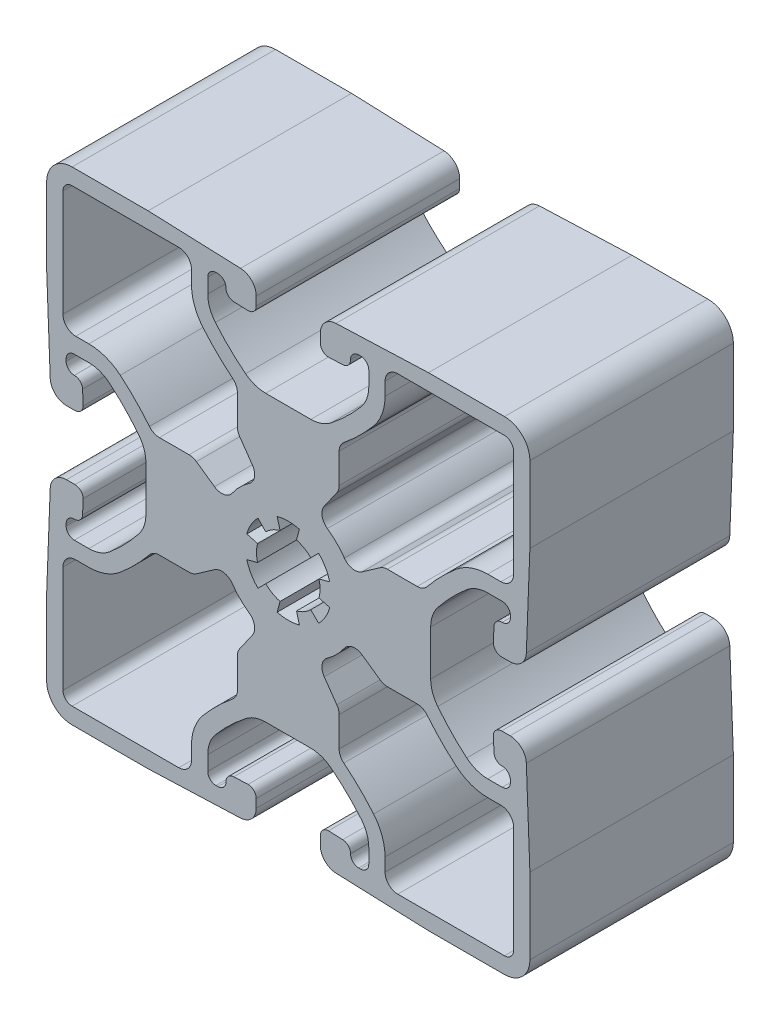
from build123d import *

# Parameters (mm, degrees)
EXTRUDE1_DEPTH = 25.4


with BuildPart() as part:
    # Sketch1 → Extrude1 (new body)
    with BuildSketch(Plane.XY):
        with BuildLine():
            Line((-26.9875, 30.1625), (-17.5006, 30.1625))
            Line((-17.5006, 30.1625), (-5.954495972, 29.718943425))
            ThreePointArc((-5.954495972, 29.718943425), (-4.568340141, 29.097433694), (-4.0005, 27.688441178))
            Line((-4.0005, 27.688441178), (-4.0005, 26.624789016))
            ThreePointArc((-4.0005, 26.624789016), (-4.29807951, 25.906368526), (-5.0165, 25.608789016))
            Line((-5.0165, 25.608789016), (-6.79818433, 25.677234424))
            ThreePointArc((-6.79818433, 25.677234424), (-7.491262245, 25.987989289), (-7.775182316, 26.692485547))
            Line((-7.775182316, 26.692485547), (-7.775182316, 26.715598436))
            ThreePointArc((-7.775182316, 26.715598436), (-8.072761826, 27.434018925), (-8.791182316, 27.731598436))
            Line((-8.791182316, 27.731598436), (-9.034069816, 27.731598436))
            ThreePointArc((-9.034069816, 27.731598436), (-9.752490306, 27.434018925), (-10.050069816, 26.715598436))
            Line((-10.050069816, 26.715598436), (-10.050069816, 24.89924596))
            ThreePointArc((-10.050069816, 24.89924596), (-9.804339489, 23.507515849), (-9.096864747, 22.284088049))
            ThreePointArc((-9.096864747, 22.284088049), (-7.306401028, 20.365015595), (-5.327460613, 18.640952309))
            ThreePointArc((-5.327460613, 18.640952309), (-4.146266021, 17.997592264), (-2.819770332, 17.775011948))
            Line((-2.819770332, 17.775011948), (2.819770332, 17.775011948))
            ThreePointArc((2.819770332, 17.775011948), (4.156955601, 18.004131576), (5.344219335, 18.66061088))
            ThreePointArc((5.344219335, 18.66061088), (7.312093916, 20.374098876), (9.09379166, 22.280436891))
            ThreePointArc((9.09379166, 22.280436891), (9.803521687, 23.50527422), (10.050069816, 24.89924596))
            Line((10.050069816, 24.89924596), (10.050069816, 26.715598436))
            ThreePointArc((10.050069816, 26.715598436), (9.752490306, 27.434018925), (9.034069816, 27.731598436))
            Line((9.034069816, 27.731598436), (8.791182316, 27.731598436))
            ThreePointArc((8.791182316, 27.731598436), (8.072761826, 27.434018925), (7.775182316, 26.715598436))
            Line((7.775182316, 26.715598436), (7.775182316, 26.692485547))
            ThreePointArc((7.775182316, 26.692485547), (7.491262245, 25.987989289), (6.79818433, 25.677234424))
            Line((6.79818433, 25.677234424), (5.0165, 25.608789016))
            ThreePointArc((5.0165, 25.608789016), (4.29807951, 25.906368526), (4.0005, 26.624789016))
            Line((4.0005, 26.624789016), (4.0005, 27.688441178))
            ThreePointArc((4.0005, 27.688441178), (4.568340141, 29.097433694), (5.954495972, 29.718943425))
            Line((5.954495972, 29.718943425), (17.5006, 30.1625))
            Line((17.5006, 30.1625), (26.9875, 30.1625))
            ThreePointArc((26.9875, 30.1625), (29.23256403, 29.23256403), (30.1625, 26.9875))
            Line((30.1625, 26.9875), (30.1625, 17.5006))
            Line((30.1625, 17.5006), (29.718943425, 5.954495972))
            ThreePointArc((29.718943425, 5.954495972), (29.097433694, 4.568340141), (27.688441178, 4.0005))
            Line((27.688441178, 4.0005), (26.624789016, 4.0005))
            ThreePointArc((26.624789016, 4.0005), (25.906368526, 4.29807951), (25.608789016, 5.0165))
            Line((25.608789016, 5.0165), (25.677234424, 6.79818433))
            ThreePointArc((25.677234424, 6.79818433), (25.987989289, 7.491262245), (26.692485547, 7.775182316))
            Line((26.692485547, 7.775182316), (26.715598436, 7.775182316))
            ThreePointArc((26.715598436, 7.775182316), (27.434018925, 8.072761826), (27.731598436, 8.791182316))
            Line((27.731598436, 8.791182316), (27.731598436, 9.034069816))
            ThreePointArc((27.731598436, 9.034069816), (27.434018925, 9.752490306), (26.715598436, 10.050069816))
            Line((26.715598436, 10.050069816), (24.89924596, 10.050069816))
            ThreePointArc((24.89924596, 10.050069816), (23.507515849, 9.804339489), (22.284088049, 9.096864747))
            ThreePointArc((22.284088049, 9.096864747), (20.365015595, 7.306401028), (18.640952309, 5.327460613))
            ThreePointArc((18.640952309, 5.327460613), (17.996266106, 4.142432499), (17.775011948, 2.811658842))
            Line((17.775011948, 2.811658842), (17.775011948, -2.819770332))
            ThreePointArc((17.775011948, -2.819770332), (18.004131576, -4.156955601), (18.66061088, -5.344219335))
            ThreePointArc((18.66061088, -5.344219335), (20.374098876, -7.312093916), (22.280436891, -9.09379166))
            ThreePointArc((22.280436891, -9.09379166), (23.50527422, -9.803521687), (24.89924596, -10.050069816))
            Line((24.89924596, -10.050069816), (26.715598436, -10.050069816))
            ThreePointArc((26.715598436, -10.050069816), (27.434018925, -9.752490306), (27.731598436, -9.034069816))
            Line((27.731598436, -9.034069816), (27.731598436, -8.791182316))
            ThreePointArc((27.731598436, -8.791182316), (27.434018925, -8.072761826), (26.715598436, -7.775182316))
            Line((26.715598436, -7.775182316), (26.692485547, -7.775182316))
            ThreePointArc((26.692485547, -7.775182316), (25.987989289, -7.491262245), (25.677234424, -6.79818433))
            Line((25.677234424, -6.79818433), (25.608789016, -5.0165))
            ThreePointArc((25.608789016, -5.0165), (25.906368526, -4.29807951), (26.624789016, -4.0005))
            Line((26.624789016, -4.0005), (27.688441178, -4.0005))
            ThreePointArc((27.688441178, -4.0005), (29.097433694, -4.568340141), (29.718943425, -5.954495972))
            Line((29.718943425, -5.954495972), (30.1625, -17.5006))
            Line((30.1625, -17.5006), (30.1625, -26.9875))
            ThreePointArc((30.1625, -26.9875), (29.23256403, -29.23256403), (26.9875, -30.1625))
            Line((26.9875, -30.1625), (17.5006, -30.1625))
            Line((17.5006, -30.1625), (5.954495972, -29.718943425))
            ThreePointArc((5.954495972, -29.718943425), (4.568340141, -29.097433694), (4.0005, -27.688441178))
            Line((4.0005, -27.688441178), (4.0005, -26.624789016))
            ThreePointArc((4.0005, -26.624789016), (4.29807951, -25.906368526), (5.0165, -25.608789016))
            Line((5.0165, -25.608789016), (6.79818433, -25.677234424))
            ThreePointArc((6.79818433, -25.677234424), (7.491262245, -25.987989289), (7.775182316, -26.692485547))
            Line((7.775182316, -26.692485547), (7.775182316, -26.715598436))
            ThreePointArc((7.775182316, -26.715598436), (8.072761826, -27.434018925), (8.791182316, -27.731598436))
            Line((8.791182316, -27.731598436), (9.034069816, -27.731598436))
            ThreePointArc((9.034069816, -27.731598436), (9.752490306, -27.434018925), (10.050069816, -26.715598436))
            Line((10.050069816, -26.715598436), (10.050069816, -24.89924596))
            ThreePointArc((10.050069816, -24.89924596), (9.804339489, -23.507515849), (9.096864674, -22.28408811))
            ThreePointArc((9.096864674, -22.28408811), (7.306400962, -20.365015663), (5.327460613, -18.640952309))
            ThreePointArc((5.327460613, -18.640952309), (4.142432499, -17.996266106), (2.811658842, -17.775011948))
            Line((2.811658842, -17.775011948), (-2.811658842, -17.775011948))
            ThreePointArc((-2.811658842, -17.775011948), (-4.153127078, -18.002795196), (-5.344219335, -18.66061088))
            ThreePointArc((-5.344219335, -18.66061088), (-7.312093916, -20.374098876), (-9.09379166, -22.280436891))
            ThreePointArc((-9.09379166, -22.280436891), (-9.803521687, -23.50527422), (-10.050069816, -24.89924596))
            Line((-10.050069816, -24.89924596), (-10.050069816, -26.715598436))
            ThreePointArc((-10.050069816, -26.715598436), (-9.752490306, -27.434018925), (-9.034069816, -27.731598436))
            Line((-9.034069816, -27.731598436), (-8.791182316, -27.731598436))
            ThreePointArc((-8.791182316, -27.731598436), (-8.072761826, -27.434018925), (-7.775182316, -26.715598436))
            Line((-7.775182316, -26.715598436), (-7.775182316, -26.692485547))
            ThreePointArc((-7.775182316, -26.692485547), (-7.491262245, -25.987989289), (-6.79818433, -25.677234424))
            Line((-6.79818433, -25.677234424), (-5.0165, -25.608789016))
            ThreePointArc((-5.0165, -25.608789016), (-4.29807951, -25.906368526), (-4.0005, -26.624789016))
            Line((-4.0005, -26.624789016), (-4.0005, -27.688441178))
            ThreePointArc((-4.0005, -27.688441178), (-4.568340141, -29.097433694), (-5.954495972, -29.718943425))
            Line((-5.954495972, -29.718943425), (-17.5006, -30.1625))
            Line((-17.5006, -30.1625), (-26.9875, -30.1625))
            ThreePointArc((-26.9875, -30.1625), (-29.23256403, -29.23256403), (-30.1625, -26.9875))
            Line((-30.1625, -26.9875), (-30.1625, -17.5006))
            Line((-30.1625, -17.5006), (-29.718943425, -5.954495972))
            ThreePointArc((-29.718943425, -5.954495972), (-29.097433694, -4.568340141), (-27.688441178, -4.0005))
            Line((-27.688441178, -4.0005), (-26.624789016, -4.0005))
            ThreePointArc((-26.624789016, -4.0005), (-25.906368526, -4.29807951), (-25.608789016, -5.0165))
            Line((-25.608789016, -5.0165), (-25.677234424, -6.79818433))
            ThreePointArc((-25.677234424, -6.79818433), (-25.987989289, -7.491262245), (-26.692485547, -7.775182316))
            Line((-26.692485547, -7.775182316), (-26.715598436, -7.775182316))
            ThreePointArc((-26.715598436, -7.775182316), (-27.434018925, -8.072761826), (-27.731598436, -8.791182316))
            Line((-27.731598436, -8.791182316), (-27.731598436, -9.034069816))
            ThreePointArc((-27.731598436, -9.034069816), (-27.434018925, -9.752490306), (-26.715598436, -10.050069816))
            Line((-26.715598436, -10.050069816), (-24.89924596, -10.050069816))
            ThreePointArc((-24.89924596, -10.050069816), (-23.507515849, -9.804339489), (-22.28408811, -9.096864674))
            ThreePointArc((-22.28408811, -9.096864674), (-20.365015663, -7.306400962), (-18.640952309, -5.327460613))
            ThreePointArc((-18.640952309, -5.327460613), (-17.997592264, -4.146266021), (-17.775011948, -2.819770332))
            Line((-17.775011948, -2.819770332), (-17.775011948, 2.811658842))
            ThreePointArc((-17.775011948, 2.811658842), (-18.002795196, 4.153127078), (-18.66061088, 5.344219335))
            ThreePointArc((-18.66061088, 5.344219335), (-20.374098876, 7.312093916), (-22.280436891, 9.09379166))
            ThreePointArc((-22.280436891, 9.09379166), (-23.50527422, 9.803521687), (-24.89924596, 10.050069816))
            Line((-24.89924596, 10.050069816), (-26.715598436, 10.050069816))
            ThreePointArc((-26.715598436, 10.050069816), (-27.434018925, 9.752490306), (-27.731598436, 9.034069816))
            Line((-27.731598436, 9.034069816), (-27.731598436, 8.791182316))
            ThreePointArc((-27.731598436, 8.791182316), (-27.434018925, 8.072761826), (-26.715598436, 7.775182316))
            Line((-26.715598436, 7.775182316), (-26.692485547, 7.775182316))
            ThreePointArc((-26.692485547, 7.775182316), (-25.987989289, 7.491262245), (-25.677234424, 6.79818433))
            Line((-25.677234424, 6.79818433), (-25.608789016, 5.0165))
            ThreePointArc((-25.608789016, 5.0165), (-25.906368526, 4.29807951), (-26.624789016, 4.0005))
            Line((-26.624789016, 4.0005), (-27.688441178, 4.0005))
            ThreePointArc((-27.688441178, 4.0005), (-29.097433694, 4.568340141), (-29.718943425, 5.954495972))
            Line((-29.718943425, 5.954495972), (-30.1625, 17.5006))
            Line((-30.1625, 17.5006), (-30.1625, 26.9875))
            ThreePointArc((-30.1625, 26.9875), (-29.23256403, 29.23256403), (-26.9875, 30.1625))
        make_face()
        with BuildLine():
            Line((11.464484235, -6.06290387), (9.214422648, -4.487393786))
            ThreePointArc((9.214422648, -4.487393786), (8.026518785, -4.224713358), (7.001506496, -4.88005022))
            ThreePointArc((7.001506496, -4.88005022), (6.034732113, -6.034732113), (4.88005022, -7.001506496))
            ThreePointArc((4.88005022, -7.001506496), (4.224713358, -8.026518785), (4.487393786, -9.214422648))
            Line((4.487393786, -9.214422648), (6.06290387, -11.464484235))
            ThreePointArc((6.06290387, -11.464484235), (6.276525659, -11.897666371), (6.35, -12.375036827))
            Line((6.35, -12.375036827), (6.35, -16.093086737))
            ThreePointArc((6.35, -16.093086737), (6.50433466, -16.775870275), (6.937330217, -17.325895179))
            ThreePointArc((6.937330217, -17.325895179), (8.881633572, -19.062834838), (10.652262139, -20.976509154))
            ThreePointArc((10.652262139, -20.976509154), (11.713474326, -22.811650794), (12.082069816, -24.89924596))
            Line((12.082069816, -24.89924596), (12.082069816, -26.543))
            ThreePointArc((12.082069816, -26.543), (12.547037801, -27.665532015), (13.669569816, -28.1305))
            Line((13.669569816, -28.1305), (26.9875, -28.1305))
            ThreePointArc((26.9875, -28.1305), (27.795723051, -27.795723051), (28.1305, -26.9875))
            Line((28.1305, -26.9875), (28.1305, -13.669569816))
            ThreePointArc((28.1305, -13.669569816), (27.665532015, -12.547037801), (26.543, -12.082069816))
            Line((26.543, -12.082069816), (24.89924596, -12.082069816))
            ThreePointArc((24.89924596, -12.082069816), (22.80828835, -11.712247623), (20.971032357, -10.647652583))
            ThreePointArc((20.971032357, -10.647652583), (19.06384238, -8.87926893), (17.332699553, -6.938212808))
            ThreePointArc((17.332699553, -6.938212808), (16.782471954, -6.50457909), (16.099175594, -6.35))
            Line((16.099175594, -6.35), (12.375036827, -6.35))
            ThreePointArc((12.375036827, -6.35), (11.897666371, -6.276525659), (11.464484235, -6.06290387))
        make_face(mode=Mode.SUBTRACT)
        with BuildLine():
            Line((-6.35, -16.093086737), (-6.35, -12.375036827))
            ThreePointArc((-6.35, -12.375036827), (-6.276525659, -11.897666371), (-6.06290387, -11.464484235))
            Line((-6.06290387, -11.464484235), (-4.487393786, -9.214422648))
            ThreePointArc((-4.487393786, -9.214422648), (-4.224713358, -8.026518785), (-4.88005022, -7.001506496))
            ThreePointArc((-4.88005022, -7.001506496), (-6.034732113, -6.034732113), (-7.001506496, -4.88005022))
            ThreePointArc((-7.001506496, -4.88005022), (-8.026518785, -4.224713358), (-9.214422648, -4.487393786))
            Line((-9.214422648, -4.487393786), (-11.464484235, -6.06290387))
            ThreePointArc((-11.464484235, -6.06290387), (-11.897666371, -6.276525659), (-12.375036827, -6.35))
            Line((-12.375036827, -6.35), (-16.099175594, -6.35))
            ThreePointArc((-16.099175594, -6.35), (-16.778619062, -6.505640302), (-17.325895179, -6.937330217))
            ThreePointArc((-17.325895179, -6.937330217), (-19.062834838, -8.881633572), (-20.976509154, -10.652262139))
            ThreePointArc((-20.976509154, -10.652262139), (-22.811650794, -11.713474326), (-24.89924596, -12.082069816))
            Line((-24.89924596, -12.082069816), (-26.543, -12.082069816))
            ThreePointArc((-26.543, -12.082069816), (-27.665532015, -12.547037801), (-28.1305, -13.669569816))
            Line((-28.1305, -13.669569816), (-28.1305, -26.9875))
            ThreePointArc((-28.1305, -26.9875), (-27.795723051, -27.795723051), (-26.9875, -28.1305))
            Line((-26.9875, -28.1305), (-13.669569816, -28.1305))
            ThreePointArc((-13.669569816, -28.1305), (-12.547037801, -27.665532015), (-12.082069816, -26.543))
            Line((-12.082069816, -26.543), (-12.082069816, -24.89924596))
            ThreePointArc((-12.082069816, -24.89924596), (-11.712247623, -22.80828835), (-10.647652583, -20.971032357))
            ThreePointArc((-10.647652583, -20.971032357), (-8.87926893, -19.06384238), (-6.938212808, -17.332699553))
            ThreePointArc((-6.938212808, -17.332699553), (-6.503264923, -16.779724306), (-6.35, -16.093086737))
        make_face(mode=Mode.SUBTRACT)
        with BuildLine():
            Line((6.06290387, 11.464484235), (4.487393786, 9.214422648))
            ThreePointArc((4.487393786, 9.214422648), (4.224713358, 8.026518785), (4.88005022, 7.001506496))
            ThreePointArc((4.88005022, 7.001506496), (6.034732113, 6.034732113), (7.001506496, 4.88005022))
            ThreePointArc((7.001506496, 4.88005022), (8.026518785, 4.224713358), (9.214422648, 4.487393786))
            Line((9.214422648, 4.487393786), (11.464484235, 6.06290387))
            ThreePointArc((11.464484235, 6.06290387), (11.897666371, 6.276525659), (12.375036827, 6.35))
            Line((12.375036827, 6.35), (16.093086737, 6.35))
            ThreePointArc((16.093086737, 6.35), (16.775870275, 6.50433466), (17.325895179, 6.937330217))
            ThreePointArc((17.325895179, 6.937330217), (19.062834838, 8.881633572), (20.976509154, 10.652262139))
            ThreePointArc((20.976509154, 10.652262139), (22.811650794, 11.713474326), (24.89924596, 12.082069816))
            Line((24.89924596, 12.082069816), (26.543, 12.082069816))
            ThreePointArc((26.543, 12.082069816), (27.665532015, 12.547037801), (28.1305, 13.669569816))
            Line((28.1305, 13.669569816), (28.1305, 26.9875))
            ThreePointArc((28.1305, 26.9875), (27.795723051, 27.795723051), (26.9875, 28.1305))
            Line((26.9875, 28.1305), (13.669569816, 28.1305))
            ThreePointArc((13.669569816, 28.1305), (12.547037801, 27.665532015), (12.082069816, 26.543))
            Line((12.082069816, 26.543), (12.082069816, 24.89924596))
            ThreePointArc((12.082069816, 24.89924596), (11.712247623, 22.80828835), (10.647652583, 20.971032357))
            ThreePointArc((10.647652583, 20.971032357), (8.87926893, 19.06384238), (6.938212808, 17.332699553))
            ThreePointArc((6.938212808, 17.332699553), (6.50457909, 16.782471954), (6.35, 16.099175594))
            Line((6.35, 16.099175594), (6.35, 12.375036827))
            ThreePointArc((6.35, 12.375036827), (6.276525659, 11.897666371), (6.06290387, 11.464484235))
        make_face(mode=Mode.SUBTRACT)
        with BuildLine():
            Line((5.176782873, -1.38711479), (3.833518123, -1.027188085))
            ThreePointArc((3.833518123, -1.027188085), (3.96875, 0), (3.833518123, 1.027188085))
            Line((3.833518123, 1.027188085), (5.176782873, 1.38711479))
            ThreePointArc((5.176782873, 1.38711479), (4.641376549, 2.6797), (3.789668083, 3.789668083))
            Line((3.789668083, 3.789668083), (2.806330038, 2.806330038))
            ThreePointArc((2.806330038, 2.806330038), (1.984375, 3.437038321), (1.027188085, 3.833518123))
            Line((1.027188085, 3.833518123), (1.38711479, 5.176782873))
            ThreePointArc((1.38711479, 5.176782873), (0, 5.3594), (-1.38711479, 5.176782873))
            Line((-1.38711479, 5.176782873), (-1.027188085, 3.833518123))
            ThreePointArc((-1.027188085, 3.833518123), (-1.984375, 3.437038321), (-2.806330038, 2.806330038))
            Line((-2.806330038, 2.806330038), (-3.789668083, 3.789668083))
            ThreePointArc((-3.789668083, 3.789668083), (-4.641376549, 2.6797), (-5.176782873, 1.38711479))
            Line((-5.176782873, 1.38711479), (-3.833518123, 1.027188085))
            ThreePointArc((-3.833518123, 1.027188085), (-3.96875, 0), (-3.833518123, -1.027188085))
            Line((-3.833518123, -1.027188085), (-5.176782873, -1.38711479))
            ThreePointArc((-5.176782873, -1.38711479), (-4.641376549, -2.6797), (-3.789668083, -3.789668083))
            Line((-3.789668083, -3.789668083), (-2.806330038, -2.806330038))
            ThreePointArc((-2.806330038, -2.806330038), (-1.984375, -3.437038321), (-1.027188085, -3.833518123))
            Line((-1.027188085, -3.833518123), (-1.38711479, -5.176782873))
            ThreePointArc((-1.38711479, -5.176782873), (0, -5.3594), (1.38711479, -5.176782873))
            Line((1.38711479, -5.176782873), (1.027188085, -3.833518123))
            ThreePointArc((1.027188085, -3.833518123), (1.984375, -3.437038321), (2.806330038, -2.806330038))
            Line((2.806330038, -2.806330038), (3.789668083, -3.789668083))
            ThreePointArc((3.789668083, -3.789668083), (4.641376549, -2.6797), (5.176782873, -1.38711479))
        make_face(mode=Mode.SUBTRACT)
        with BuildLine():
            Line((-26.543, 12.082069816), (-24.89924596, 12.082069816))
            ThreePointArc((-24.89924596, 12.082069816), (-22.80828835, 11.712247623), (-20.971032357, 10.647652583))
            ThreePointArc((-20.971032357, 10.647652583), (-19.06384238, 8.87926893), (-17.332699553, 6.938212808))
            ThreePointArc((-17.332699553, 6.938212808), (-16.779724306, 6.503264923), (-16.093086737, 6.35))
            Line((-16.093086737, 6.35), (-12.375036827, 6.35))
            ThreePointArc((-12.375036827, 6.35), (-11.897666371, 6.276525659), (-11.464484235, 6.06290387))
            Line((-11.464484235, 6.06290387), (-9.214422648, 4.487393786))
            ThreePointArc((-9.214422648, 4.487393786), (-8.026518785, 4.224713358), (-7.001506496, 4.88005022))
            ThreePointArc((-7.001506496, 4.88005022), (-6.034732113, 6.034732113), (-4.88005022, 7.001506496))
            ThreePointArc((-4.88005022, 7.001506496), (-4.224713358, 8.026518785), (-4.487393786, 9.214422648))
            Line((-4.487393786, 9.214422648), (-6.06290387, 11.464484235))
            ThreePointArc((-6.06290387, 11.464484235), (-6.276525659, 11.897666371), (-6.35, 12.375036827))
            Line((-6.35, 12.375036827), (-6.35, 16.099175594))
            ThreePointArc((-6.35, 16.099175594), (-6.505640302, 16.778619062), (-6.937330217, 17.325895179))
            ThreePointArc((-6.937330217, 17.325895179), (-8.881633638, 19.06283477), (-10.652262212, 20.976509093))
            ThreePointArc((-10.652262212, 20.976509093), (-11.713474326, 22.811650794), (-12.082069816, 24.89924596))
            Line((-12.082069816, 24.89924596), (-12.082069816, 26.543))
            ThreePointArc((-12.082069816, 26.543), (-12.547037801, 27.665532015), (-13.669569816, 28.1305))
            Line((-13.669569816, 28.1305), (-26.9875, 28.1305))
            ThreePointArc((-26.9875, 28.1305), (-27.795723051, 27.795723051), (-28.1305, 26.9875))
            Line((-28.1305, 26.9875), (-28.1305, 13.669569816))
            ThreePointArc((-28.1305, 13.669569816), (-27.665532015, 12.547037801), (-26.543, 12.082069816))
        make_face(mode=Mode.SUBTRACT)
    extrude(amount=EXTRUDE1_DEPTH)


solid = part.part
